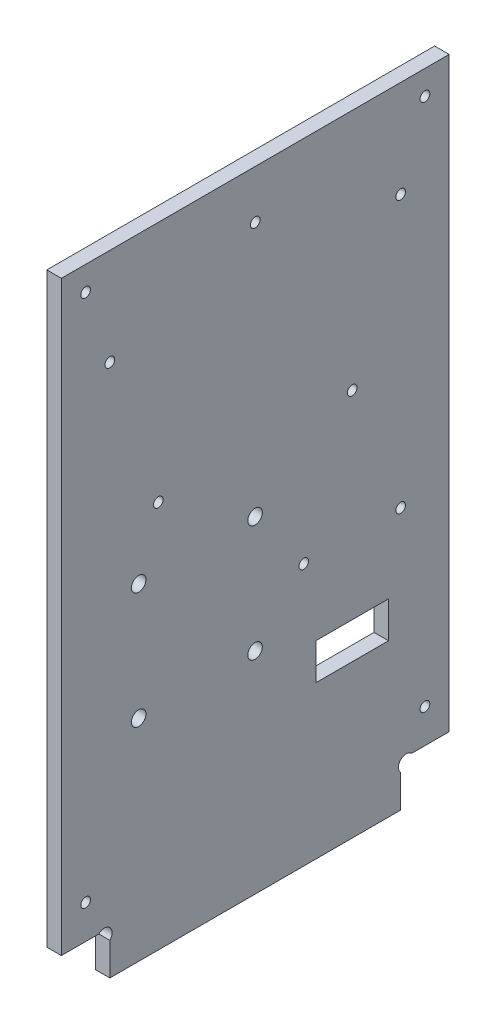
from build123d import *

# Parameters (mm, degrees)
EXTRUSION1_DEPTH        = 3
ESQUISSE2_R             = 1
ESQUISSE2_R_2           = 1.5
ENL_V_MAT_EXTRU_1_DEPTH = 4
ESQUISSE3_W             = 15
ESQUISSE3_H             = 7.5
ENL_V_MAT_EXTRU_2_DEPTH = 4
ESQUISSE4_R             = 1
ENL_V_MAT_EXTRU_3_DEPTH = 4


with BuildPart() as part:
    # Esquisse1 → Extrusion1 (new body)
    with BuildSketch(Plane(origin=(0, 0, 0), x_dir=(0, 0, -1), z_dir=(1, 0, 0))):
        with BuildLine():
            Line((10, 6.7372583), (10, 0))
            Line((10, 0), (70, 0))
            Line((70, 0), (70, 6.7372583))
            ThreePointArc((70, 6.7372583), (70, 9), (72.2627417, 9))
            Line((72.2627417, 9), (80, 9))
            Line((80, 9), (80, 130))
            Line((80, 130), (0, 130))
            Line((0, 130), (0, 9))
            Line((0, 9), (7.7372583, 9))
            ThreePointArc((7.7372583, 9), (10, 9), (10, 6.7372583))
        make_face()
    extrude(amount=EXTRUSION1_DEPTH)

    # Esquisse2 → Enlèv. mat.-Extru.1 (cut, through all)
    with BuildSketch(Plane(origin=(3, 0, 0), x_dir=(0, 0, -1), z_dir=(1, 0, 0))):
        with Locations((60, 80)):
            Circle(ESQUISSE2_R)
        with Locations((10, 110)):
            Circle(ESQUISSE2_R)
        with Locations(Location((20, 80, 0), (0, 0, 180))):  # turned: the seam where the file's is
            Circle(ESQUISSE2_R)
        with Locations((70, 110)):
            Circle(ESQUISSE2_R)
        with Locations((15.95, 67.45)):
            Circle(ESQUISSE2_R_2)
        with Locations((15.95, 43.45)):
            Circle(ESQUISSE2_R_2)
        with Locations((39.95, 43.45)):
            Circle(ESQUISSE2_R_2)
        with Locations((39.95, 67.45)):
            Circle(ESQUISSE2_R_2)
        with Locations((40, 120)):
            Circle(ESQUISSE2_R)
        with Locations((70, 54)):
            Circle(ESQUISSE2_R)
        with Locations((50, 54)):
            Circle(ESQUISSE2_R)
    extrude(amount=-ENL_V_MAT_EXTRU_1_DEPTH, mode=Mode.SUBTRACT)

    # Esquisse3 → Enlèv. mat.-Extru.2 (cut, through all)
    with BuildSketch(Plane.ZY):
        with Locations((-60, 35.25)):
            Rectangle(ESQUISSE3_W, ESQUISSE3_H)
    extrude(amount=-ENL_V_MAT_EXTRU_2_DEPTH, mode=Mode.SUBTRACT)

    # Esquisse4 → Enlèv. mat.-Extru.3 (cut, through all)
    with BuildSketch(Plane(origin=(3, 0, 0), x_dir=(0, 0, -1), z_dir=(1, 0, 0))):
        with Locations((5, 125)):
            Circle(ESQUISSE4_R)
        with Locations((75, 125)):
            Circle(ESQUISSE4_R)
        with Locations((75, 16)):
            Circle(ESQUISSE4_R)
        with Locations((5, 16)):
            Circle(ESQUISSE4_R)
    extrude(amount=-ENL_V_MAT_EXTRU_3_DEPTH, mode=Mode.SUBTRACT)


solid = part.part
